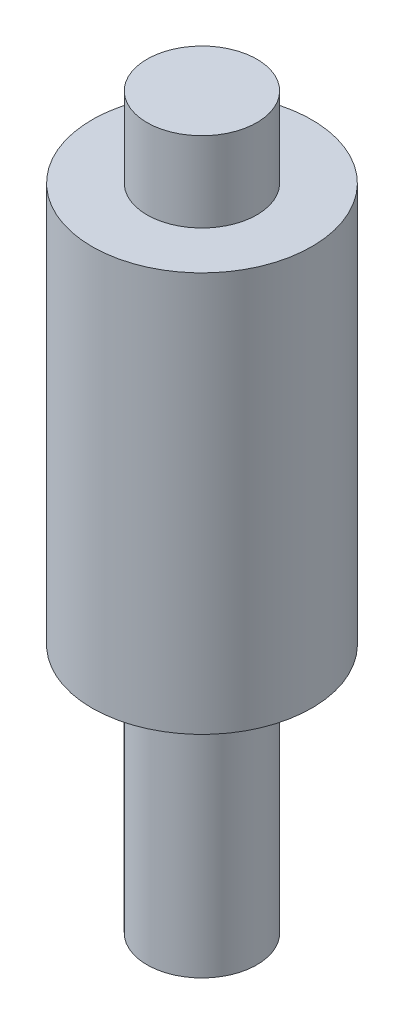
from build123d import *

# Parameters (mm, degrees)
SKETCH1_R           = 2.2
BOSS_EXTRUDE1_DEPTH = 8
SKETCH2_R           = 1.1
BOSS_EXTRUDE2_DEPTH = 1.6
SKETCH3_R           = 1.1
BOSS_EXTRUDE3_DEPTH = 5


with BuildPart() as part:
    # Sketch1 → Boss-Extrude1 (new body)
    with BuildSketch(Plane(origin=(0, 0, 0), x_dir=(1, 0, 0), z_dir=(0, 1, 0))):
        Circle(SKETCH1_R)
    extrude(amount=BOSS_EXTRUDE1_DEPTH)

    # Sketch2 → Boss-Extrude2 (add)
    with BuildSketch(Plane(origin=(0, 8, 0), x_dir=(1, 0, 0), z_dir=(0, 1, 0))):
        Circle(SKETCH2_R)
    extrude(amount=BOSS_EXTRUDE2_DEPTH)

    # Sketch3 → Boss-Extrude3 (add)
    with BuildSketch(Plane.XZ):
        Circle(SKETCH3_R)
    extrude(amount=BOSS_EXTRUDE3_DEPTH)


solid = part.part
